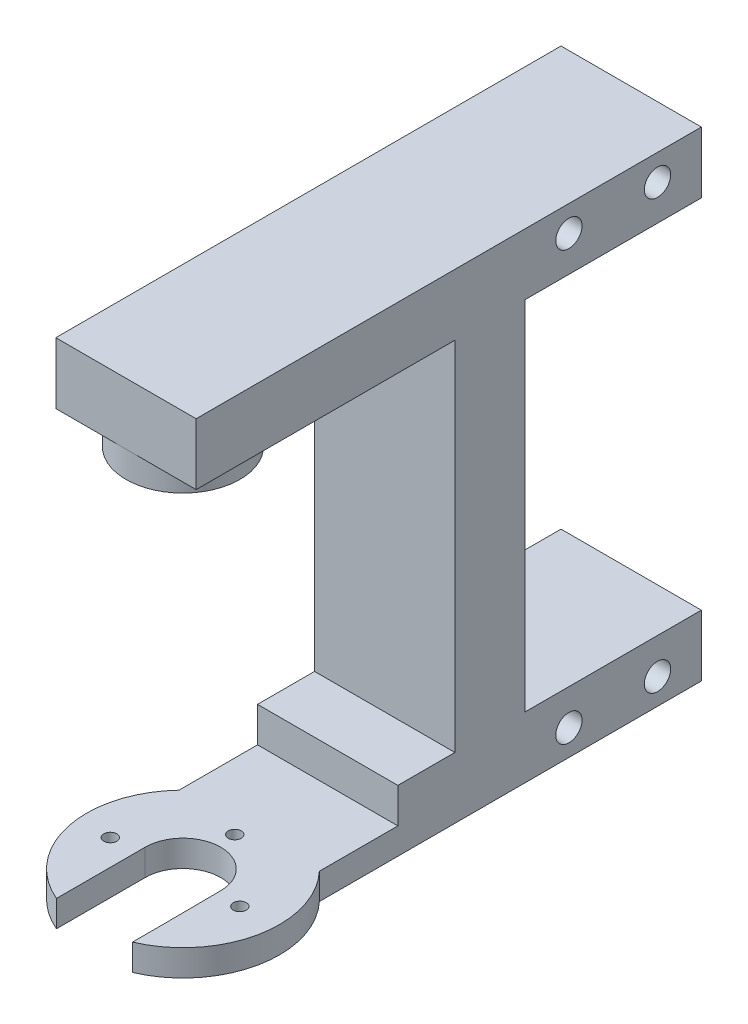
from build123d import *

# Parameters (mm, degrees)
EXTRUDE_1_DEPTH     = 16
CUT_EXTRUDE_1_REACH = 76.645
CUT_EXTRUDE_2_DEPTH = 3
CUT_EXTRUDE_5_REACH = 76.645
SKETCH_7_W          = 23
SKETCH_7_H          = 4
SKETCH_10_R         = 11
EXTRUDE_3_DEPTH     = 3
CUT_EXTRUDE_4_REACH = 79.162
CUT_EXTRUDE_6_REACH = 83.675
SKETCH_11_R         = 0.74


with BuildPart() as part:
    # Sketch 3D_2 → Extrude 1 (new body)
    with BuildSketch(Plane(origin=(0, 0, 0), x_dir=(0, -0.6130856686286148, -0.7900164320583494), z_dir=(1, 0, 0))):
        Polygon((0, 0), (10.270213617, 7.970113692), (8.430956611, 10.340162988), (21.46622774, 20.456076521), (46.418814453, -11.697592264), (23.113329707, -29.783619489), (27.404929388, -35.313734513), (72.909875874, 0), (68.618276194, 5.530115024), (52.738945909, -6.792906915), (27.786359196, 25.36076187), (43.665689481, 37.683783809), (39.3740898, 43.213898834), (-6.130856686, 7.900164321), align=None)
    extrude(amount=-EXTRUDE_1_DEPTH)

    # Sketch 3 → Cut-Extrude 1 (cut, up to next)
    with BuildSketch(Plane(origin=(0, 0, 0), x_dir=(0, 0, -1), z_dir=(1, 0, 0)), mode=Mode.PRIVATE) as cut_extrude_1_sk1:
        with BuildLine():
            ThreePointArc((41, 7.05), (41.439339828, 5.989339828), (42.5, 5.55))
            Line((42.5, 5.55), (42.5, 7.05))
            Line((42.5, 7.05), (41, 7.05))
        make_face()
    cut_extrude_1_tool1 = extrude(cut_extrude_1_sk1.sketch, amount=-CUT_EXTRUDE_1_REACH, mode=Mode.PRIVATE) & part.part
    # Sketch 3 → Cut-Extrude 1 (cut, up to next)
    with BuildSketch(Plane(origin=(0, 0, 0), x_dir=(0, 0, -1), z_dir=(1, 0, 0)), mode=Mode.PRIVATE) as cut_extrude_1_sk2:
        with BuildLine():
            Line((42.5, 7.05), (42.5, 5.55))
            ThreePointArc((42.5, 5.55), (43.560660172, 5.989339828), (44, 7.05))
            ThreePointArc((44, 7.05), (42.5, 8.55), (41, 7.05))
            Line((41, 7.05), (42.5, 7.05))
        make_face()
    cut_extrude_1_tool2 = extrude(cut_extrude_1_sk2.sketch, amount=-CUT_EXTRUDE_1_REACH, mode=Mode.PRIVATE) & part.part
    # Sketch 3 → Cut-Extrude 1 (cut, up to next)
    with BuildSketch(Plane(origin=(0, 0, 0), x_dir=(0, 0, -1), z_dir=(1, 0, 0)), mode=Mode.PRIVATE) as cut_extrude_1_sk3:
        with BuildLine():
            ThreePointArc((41, 7.05), (41.439339828, 5.989339828), (42.5, 5.55))
            Line((42.5, 5.55), (42.5, 7.05))
            Line((42.5, 7.05), (41, 7.05))
        make_face()
    cut_extrude_1_tool3 = extrude(cut_extrude_1_sk3.sketch, amount=-CUT_EXTRUDE_1_REACH, mode=Mode.PRIVATE) & part.part
    # Sketch 3 → Cut-Extrude 1 (cut, up to next)
    with BuildSketch(Plane(origin=(0, 0, 0), x_dir=(0, 0, -1), z_dir=(1, 0, 0)), mode=Mode.PRIVATE) as cut_extrude_1_sk4:
        with BuildLine():
            Line((42.5, 7.05), (42.5, 5.55))
            ThreePointArc((42.5, 5.55), (43.560660172, 5.989339828), (44, 7.05))
            ThreePointArc((44, 7.05), (42.5, 8.55), (41, 7.05))
            Line((41, 7.05), (42.5, 7.05))
        make_face()
    cut_extrude_1_tool4 = extrude(cut_extrude_1_sk4.sketch, amount=-CUT_EXTRUDE_1_REACH, mode=Mode.PRIVATE) & part.part
    # Sketch 3 → Cut-Extrude 1 (cut, up to next)
    with BuildSketch(Plane(origin=(0, 0, 0), x_dir=(0, 0, -1), z_dir=(1, 0, 0)), mode=Mode.PRIVATE) as cut_extrude_1_sk5:
        with BuildLine():
            ThreePointArc((54.1, 7.05), (51.539339828, 8.110660172), (52.6, 5.55))
            Line((52.6, 5.55), (52.6, 7.05))
            Line((52.6, 7.05), (54.1, 7.05))
        make_face()
    cut_extrude_1_tool5 = extrude(cut_extrude_1_sk5.sketch, amount=-CUT_EXTRUDE_1_REACH, mode=Mode.PRIVATE) & part.part
    # Sketch 3 → Cut-Extrude 1 (cut, up to next)
    with BuildSketch(Plane(origin=(0, 0, 0), x_dir=(0, 0, -1), z_dir=(1, 0, 0)), mode=Mode.PRIVATE) as cut_extrude_1_sk6:
        with BuildLine():
            Line((52.6, 7.05), (52.6, 5.55))
            ThreePointArc((52.6, 5.55), (53.660660172, 5.989339828), (54.1, 7.05))
            Line((54.1, 7.05), (52.6, 7.05))
        make_face()
    cut_extrude_1_tool6 = extrude(cut_extrude_1_sk6.sketch, amount=-CUT_EXTRUDE_1_REACH, mode=Mode.PRIVATE) & part.part
    # Sketch 3 → Cut-Extrude 1 (cut, up to next)
    with BuildSketch(Plane(origin=(0, 0, 0), x_dir=(0, 0, -1), z_dir=(1, 0, 0)), mode=Mode.PRIVATE) as cut_extrude_1_sk7:
        with BuildLine():
            ThreePointArc((54.1, 7.05), (51.539339828, 8.110660172), (52.6, 5.55))
            Line((52.6, 5.55), (52.6, 7.05))
            Line((52.6, 7.05), (54.1, 7.05))
        make_face()
    cut_extrude_1_tool7 = extrude(cut_extrude_1_sk7.sketch, amount=-CUT_EXTRUDE_1_REACH, mode=Mode.PRIVATE) & part.part
    # Sketch 3 → Cut-Extrude 1 (cut, up to next)
    with BuildSketch(Plane(origin=(0, 0, 0), x_dir=(0, 0, -1), z_dir=(1, 0, 0)), mode=Mode.PRIVATE) as cut_extrude_1_sk8:
        with BuildLine():
            Line((52.6, 7.05), (52.6, 5.55))
            ThreePointArc((52.6, 5.55), (53.660660172, 5.989339828), (54.1, 7.05))
            Line((54.1, 7.05), (52.6, 7.05))
        make_face()
    cut_extrude_1_tool8 = extrude(cut_extrude_1_sk8.sketch, amount=-CUT_EXTRUDE_1_REACH, mode=Mode.PRIVATE) & part.part
    # Sketch 3 → Cut-Extrude 1 (cut, up to next)
    with BuildSketch(Plane(origin=(0, 0, 0), x_dir=(0, 0, -1), z_dir=(1, 0, 0)), mode=Mode.PRIVATE) as cut_extrude_1_sk9:
        with BuildLine():
            ThreePointArc((44, -41.75), (43.560660172, -40.689339828), (42.5, -40.25))
            Line((42.5, -40.25), (42.5, -41.75))
            Line((42.5, -41.75), (41, -41.75))
            ThreePointArc((41, -41.75), (42.5, -43.25), (44, -41.75))
        make_face()
    cut_extrude_1_tool9 = extrude(cut_extrude_1_sk9.sketch, amount=-CUT_EXTRUDE_1_REACH, mode=Mode.PRIVATE) & part.part
    # Sketch 3 → Cut-Extrude 1 (cut, up to next)
    with BuildSketch(Plane(origin=(0, 0, 0), x_dir=(0, 0, -1), z_dir=(1, 0, 0)), mode=Mode.PRIVATE) as cut_extrude_1_sk10:
        with BuildLine():
            Line((42.5, -41.75), (42.5, -40.25))
            ThreePointArc((42.5, -40.25), (41.439339828, -40.689339828), (41, -41.75))
            Line((41, -41.75), (42.5, -41.75))
        make_face()
    cut_extrude_1_tool10 = extrude(cut_extrude_1_sk10.sketch, amount=-CUT_EXTRUDE_1_REACH, mode=Mode.PRIVATE) & part.part
    # Sketch 3 → Cut-Extrude 1 (cut, up to next)
    with BuildSketch(Plane(origin=(0, 0, 0), x_dir=(0, 0, -1), z_dir=(1, 0, 0)), mode=Mode.PRIVATE) as cut_extrude_1_sk11:
        with BuildLine():
            ThreePointArc((44, -41.75), (43.560660172, -40.689339828), (42.5, -40.25))
            Line((42.5, -40.25), (42.5, -41.75))
            Line((42.5, -41.75), (41, -41.75))
            ThreePointArc((41, -41.75), (42.5, -43.25), (44, -41.75))
        make_face()
    cut_extrude_1_tool11 = extrude(cut_extrude_1_sk11.sketch, amount=-CUT_EXTRUDE_1_REACH, mode=Mode.PRIVATE) & part.part
    # Sketch 3 → Cut-Extrude 1 (cut, up to next)
    with BuildSketch(Plane(origin=(0, 0, 0), x_dir=(0, 0, -1), z_dir=(1, 0, 0)), mode=Mode.PRIVATE) as cut_extrude_1_sk12:
        with BuildLine():
            Line((42.5, -41.75), (42.5, -40.25))
            ThreePointArc((42.5, -40.25), (41.439339828, -40.689339828), (41, -41.75))
            Line((41, -41.75), (42.5, -41.75))
        make_face()
    cut_extrude_1_tool12 = extrude(cut_extrude_1_sk12.sketch, amount=-CUT_EXTRUDE_1_REACH, mode=Mode.PRIVATE) & part.part
    # Sketch 3 → Cut-Extrude 1 (cut, up to next)
    with BuildSketch(Plane(origin=(0, 0, 0), x_dir=(0, 0, -1), z_dir=(1, 0, 0)), mode=Mode.PRIVATE) as cut_extrude_1_sk13:
        with BuildLine():
            ThreePointArc((54.1, -41.75), (53.660660172, -40.689339828), (52.6, -40.25))
            Line((52.6, -40.25), (52.6, -41.75))
            Line((52.6, -41.75), (54.1, -41.75))
        make_face()
    cut_extrude_1_tool13 = extrude(cut_extrude_1_sk13.sketch, amount=-CUT_EXTRUDE_1_REACH, mode=Mode.PRIVATE) & part.part
    # Sketch 3 → Cut-Extrude 1 (cut, up to next)
    with BuildSketch(Plane(origin=(0, 0, 0), x_dir=(0, 0, -1), z_dir=(1, 0, 0)), mode=Mode.PRIVATE) as cut_extrude_1_sk14:
        with BuildLine():
            Line((52.6, -41.75), (52.6, -40.25))
            ThreePointArc((52.6, -40.25), (51.539339828, -42.810660172), (54.1, -41.75))
            Line((54.1, -41.75), (52.6, -41.75))
        make_face()
    cut_extrude_1_tool14 = extrude(cut_extrude_1_sk14.sketch, amount=-CUT_EXTRUDE_1_REACH, mode=Mode.PRIVATE) & part.part
    # Sketch 3 → Cut-Extrude 1 (cut, up to next)
    with BuildSketch(Plane(origin=(0, 0, 0), x_dir=(0, 0, -1), z_dir=(1, 0, 0)), mode=Mode.PRIVATE) as cut_extrude_1_sk15:
        with BuildLine():
            ThreePointArc((54.1, -41.75), (53.660660172, -40.689339828), (52.6, -40.25))
            Line((52.6, -40.25), (52.6, -41.75))
            Line((52.6, -41.75), (54.1, -41.75))
        make_face()
    cut_extrude_1_tool15 = extrude(cut_extrude_1_sk15.sketch, amount=-CUT_EXTRUDE_1_REACH, mode=Mode.PRIVATE) & part.part
    # Sketch 3 → Cut-Extrude 1 (cut, up to next)
    with BuildSketch(Plane(origin=(0, 0, 0), x_dir=(0, 0, -1), z_dir=(1, 0, 0)), mode=Mode.PRIVATE) as cut_extrude_1_sk16:
        with BuildLine():
            Line((52.6, -41.75), (52.6, -40.25))
            ThreePointArc((52.6, -40.25), (51.539339828, -42.810660172), (54.1, -41.75))
            Line((54.1, -41.75), (52.6, -41.75))
        make_face()
    cut_extrude_1_tool16 = extrude(cut_extrude_1_sk16.sketch, amount=-CUT_EXTRUDE_1_REACH, mode=Mode.PRIVATE) & part.part
    add(cut_extrude_1_tool1.solids().sort_by_distance((0, 6.41338, -41.86338))[0], mode=Mode.SUBTRACT)
    add(cut_extrude_1_tool2.solids().sort_by_distance((0, 7.262207, -42.712207))[0], mode=Mode.SUBTRACT)
    add(cut_extrude_1_tool3.solids().sort_by_distance((0, 6.41338, -41.86338))[0], mode=Mode.SUBTRACT)
    add(cut_extrude_1_tool4.solids().sort_by_distance((0, 7.262207, -42.712207))[0], mode=Mode.SUBTRACT)
    add(cut_extrude_1_tool5.solids().sort_by_distance((0, 7.262207, -52.387793))[0], mode=Mode.SUBTRACT)
    add(cut_extrude_1_tool6.solids().sort_by_distance((0, 6.41338, -53.23662))[0], mode=Mode.SUBTRACT)
    add(cut_extrude_1_tool7.solids().sort_by_distance((0, 7.262207, -52.387793))[0], mode=Mode.SUBTRACT)
    add(cut_extrude_1_tool8.solids().sort_by_distance((0, 6.41338, -53.23662))[0], mode=Mode.SUBTRACT)
    add(cut_extrude_1_tool9.solids().sort_by_distance((0, -41.962207, -42.712207))[0], mode=Mode.SUBTRACT)
    add(cut_extrude_1_tool10.solids().sort_by_distance((0, -41.11338, -41.86338))[0], mode=Mode.SUBTRACT)
    add(cut_extrude_1_tool11.solids().sort_by_distance((0, -41.962207, -42.712207))[0], mode=Mode.SUBTRACT)
    add(cut_extrude_1_tool12.solids().sort_by_distance((0, -41.11338, -41.86338))[0], mode=Mode.SUBTRACT)
    add(cut_extrude_1_tool13.solids().sort_by_distance((0, -41.11338, -53.23662))[0], mode=Mode.SUBTRACT)
    add(cut_extrude_1_tool14.solids().sort_by_distance((0, -41.962207, -52.387793))[0], mode=Mode.SUBTRACT)
    add(cut_extrude_1_tool15.solids().sort_by_distance((0, -41.11338, -53.23662))[0], mode=Mode.SUBTRACT)
    add(cut_extrude_1_tool16.solids().sort_by_distance((0, -41.962207, -52.387793))[0], mode=Mode.SUBTRACT)

    # Sketch 4 → Cut-Extrude 2 (cut)
    with BuildSketch(Plane.XZ):
        with BuildLine():
            Line((-8, 0), (-16, 0))
            Line((-16, 0), (-16, -6.5))
            Line((-16, -6.5), (-14.5, -6.5))
            ThreePointArc((-14.5, -6.5), (-12.596194078, -1.903805922), (-8, 0))
        make_face()
        with BuildLine():
            Line((-14.5, -6.5), (-16, -6.5))
            Line((-16, -6.5), (-16, -13))
            Line((-16, -13), (-8.000000015, -13))
            ThreePointArc((-8.000000015, -13), (-12.596194083, -11.096194072), (-14.5, -6.5))
        make_face()
        with BuildLine():
            Line((0, 0), (-8, 0))
            ThreePointArc((-8, 0), (-3.403805922, -1.903805922), (-1.5, -6.5))
            ThreePointArc((-1.5, -6.5), (-3.403805928, -11.096194083), (-8.000000015, -13))
            Line((-8.000000015, -13), (0, -13))
            Line((0, -13), (0, 0))
        make_face()
    extrude(amount=-CUT_EXTRUDE_2_DEPTH, mode=Mode.SUBTRACT)

    # Sketch 7 → Cut-Extrude 5 (cut, up to next)
    with BuildSketch(Plane(origin=(0, 0, 0), x_dir=(0, 0, -1), z_dir=(1, 0, 0)), mode=Mode.PRIVATE) as cut_extrude_5_sk1:
        with Locations((11.5, -39.7)):
            Rectangle(SKETCH_7_W, SKETCH_7_H)
    cut_extrude_5_tool1 = extrude(cut_extrude_5_sk1.sketch, amount=-CUT_EXTRUDE_5_REACH, mode=Mode.PRIVATE) & part.part
    add(cut_extrude_5_tool1.solids().sort_by_distance((0, -39.7, -11.5))[0], mode=Mode.SUBTRACT)

    # Sketch 10 → Extrude 3 (add)
    with BuildSketch(Plane(origin=(0, -41.7, 0), x_dir=(1, 0, 0), z_dir=(0, 1, 0))):
        with Locations((-8, 6.5)):
            Circle(SKETCH_10_R)
    extrude(amount=-EXTRUDE_3_DEPTH)

    # Sketch 5 → Cut-Extrude 4 (cut, up to next)
    with BuildSketch(Plane(origin=(0, -37.7, 0), x_dir=(1, 0, 0), z_dir=(0, 1, 0)), mode=Mode.PRIVATE) as cut_extrude_4_sk1:
        with BuildLine():
            Line((-3.7, 6.5), (-3.65658976, 0))
            Line((-3.65658976, 0), (-3.65658976, -3.60617571))
            ThreePointArc((-3.65658976, -3.60617571), (-7.976396918, -4.499974677), (-12.3, -3.624722218))
            Line((-12.3, -3.624722218), (-12.3, 0))
            Line((-12.3, 0), (-12.3, 6.5))
            ThreePointArc((-12.3, 6.5), (-8, 10.8), (-3.7, 6.5))
        make_face()
    cut_extrude_4_tool1 = extrude(cut_extrude_4_sk1.sketch, amount=-CUT_EXTRUDE_4_REACH, mode=Mode.PRIVATE) & part.part
    add(cut_extrude_4_tool1.solids().sort_by_distance((-7.989405, -37.7, -2.855539))[0], mode=Mode.SUBTRACT)

    # Sketch 11 → Cut-Extrude 6 (cut, up to next)
    with BuildSketch(Plane.XZ.offset(44.7), mode=Mode.PRIVATE) as cut_extrude_6_sk1:
        with Locations(Location((-1.05598139, -6.041375971, 0), (0, 0, 270))):
            Circle(SKETCH_11_R)
    cut_extrude_6_tool1 = extrude(cut_extrude_6_sk1.sketch, amount=-CUT_EXTRUDE_6_REACH, mode=Mode.PRIVATE) & part.part
    # Sketch 11 → Cut-Extrude 6 (cut, up to next)
    with BuildSketch(Plane.XZ.offset(44.7), mode=Mode.PRIVATE) as cut_extrude_6_sk2:
        with Locations(Location((-8.441375971, -12.84401861, 0), (0, 0, 270))):
            Circle(SKETCH_11_R)
    cut_extrude_6_tool2 = extrude(cut_extrude_6_sk2.sketch, amount=-CUT_EXTRUDE_6_REACH, mode=Mode.PRIVATE) & part.part
    # Sketch 11 → Cut-Extrude 6 (cut, up to next)
    with BuildSketch(Plane.XZ.offset(44.7), mode=Mode.PRIVATE) as cut_extrude_6_sk3:
        with Locations(Location((-15.24401861, -5.458624029, 0), (0, 0, 270))):
            Circle(SKETCH_11_R)
    cut_extrude_6_tool3 = extrude(cut_extrude_6_sk3.sketch, amount=-CUT_EXTRUDE_6_REACH, mode=Mode.PRIVATE) & part.part
    add(cut_extrude_6_tool1.solids().sort_by_distance((-1.055981, -44.7, -6.041376))[0], mode=Mode.SUBTRACT)
    add(cut_extrude_6_tool2.solids().sort_by_distance((-8.441376, -44.7, -12.844019))[0], mode=Mode.SUBTRACT)
    add(cut_extrude_6_tool3.solids().sort_by_distance((-15.244019, -44.7, -5.458624))[0], mode=Mode.SUBTRACT)


solid = part.part
